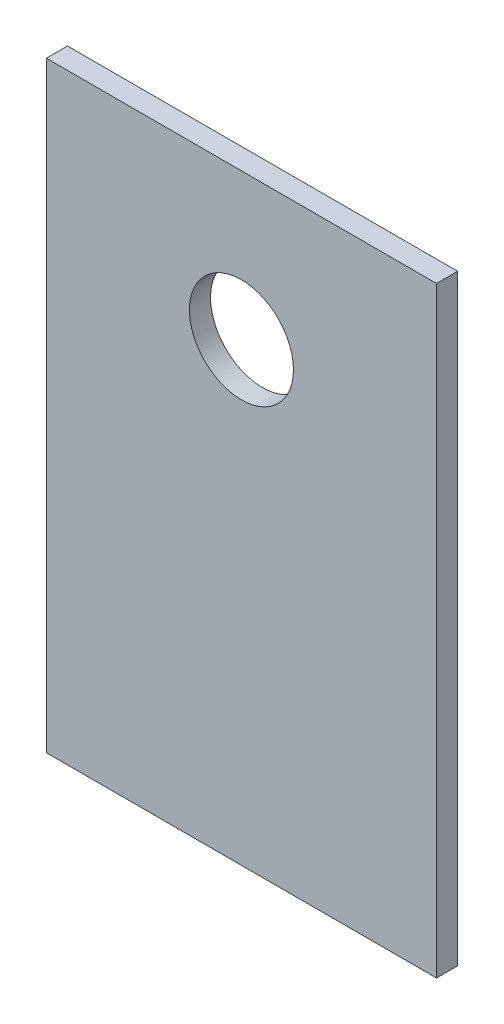
from build123d import *

# Parameters (mm, degrees)
SKETCH1_W           = 12
SKETCH1_H           = 18.5
SKETCH1_R           = 1.6
BOSS_EXTRUDE1_DEPTH = 0.65


with BuildPart() as part:
    # Sketch1 → Boss-Extrude1 (new body)
    with BuildSketch(Plane.XY):
        with Locations((0, -4.75)):
            Rectangle(SKETCH1_W, SKETCH1_H)
        Circle(SKETCH1_R, mode=Mode.SUBTRACT)
    extrude(amount=BOSS_EXTRUDE1_DEPTH)


solid = part.part
